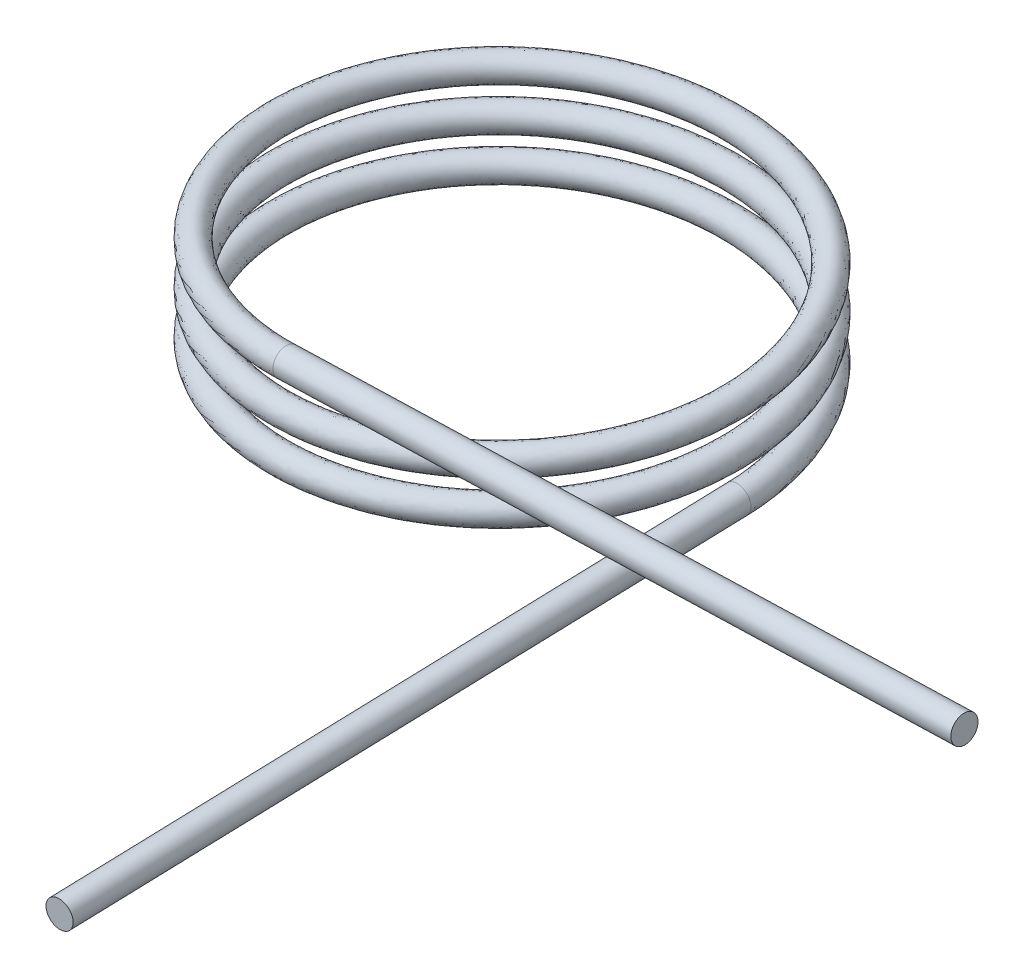
from build123d import *

# Parameters (mm, degrees)
SWEEP1_PITCH        = 6.477
SWEEP1_HEIGHT       = 17.81175
SWEEP1_RADIUS       = 33.782
SWEEP1_START_ANGLE  = 90
SWEEP1_PROFILE_R    = 2.032
SKETCH15_R          = 2.032
BOSS_EXTRUDE1_DEPTH = 101.6
SKETCH24_R          = 2.032
BOSS_EXTRUDE2_DEPTH = 101.6


with BuildPart() as part:
    # Sweep1: sweep along a helix
    with BuildLine() as sweep1_path:
        add(Helix(SWEEP1_PITCH, SWEEP1_HEIGHT, SWEEP1_RADIUS, center=(0, 0, 0), direction=(0, 1, 0), mode=Mode.PRIVATE).rotate(Axis((0, 0, 0), (0, 1, 0)), SWEEP1_START_ANGLE))
    # Sweep1 profile (on start of the path) → Sweep1 (sweep)
    with BuildSketch(Plane(origin=(33.782, 0, 0), x_dir=(0, -0.999534752, -0.030500473), z_dir=(0, 0.030500473, -0.999534752))):
        Circle(SWEEP1_PROFILE_R)
    sweep(path=sweep1_path.line, is_frenet=True)

    # Sketch15 → Boss-Extrude1 (add)
    with BuildSketch(Plane(origin=(0.54301404, 0.016569894, 0), x_dir=(0, 0, -1), z_dir=(0.999534752, 0.030500473, 0))):
        with Locations((-33.782, 17.803463125)):
            Circle(SKETCH15_R)
    extrude(amount=BOSS_EXTRUDE1_DEPTH)

    # Sketch24 → Boss-Extrude2 (add)
    with BuildSketch(Plane(origin=(0, 0, 0), x_dir=(1, 0, 0), z_dir=(0, -0.030500473, 0.999534752))):
        with Locations((33.782, 0)):
            Circle(SKETCH24_R)
    extrude(amount=BOSS_EXTRUDE2_DEPTH)


solid = part.part
